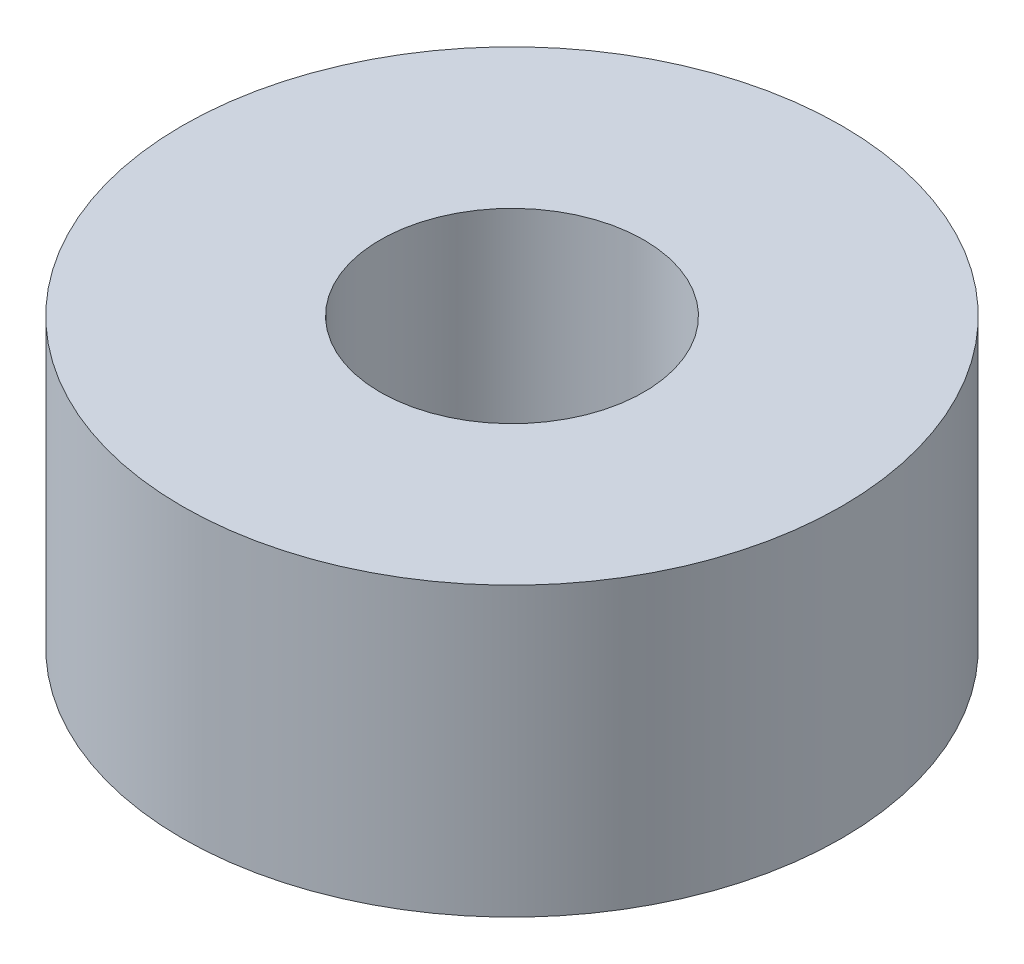
from build123d import *

# Parameters (mm, degrees)
SKETCH1_R           = 6.35
SKETCH1_R_2         = 2.54
BOSS_EXTRUDE1_DEPTH = 5.5372


with BuildPart() as part:
    # Sketch1 → Boss-Extrude1 (new body)
    with BuildSketch(Plane(origin=(0, 0, 0), x_dir=(1, 0, 0), z_dir=(0, 1, 0))):
        Circle(SKETCH1_R)
        Circle(SKETCH1_R_2, mode=Mode.SUBTRACT)
    extrude(amount=BOSS_EXTRUDE1_DEPTH)


solid = part.part
